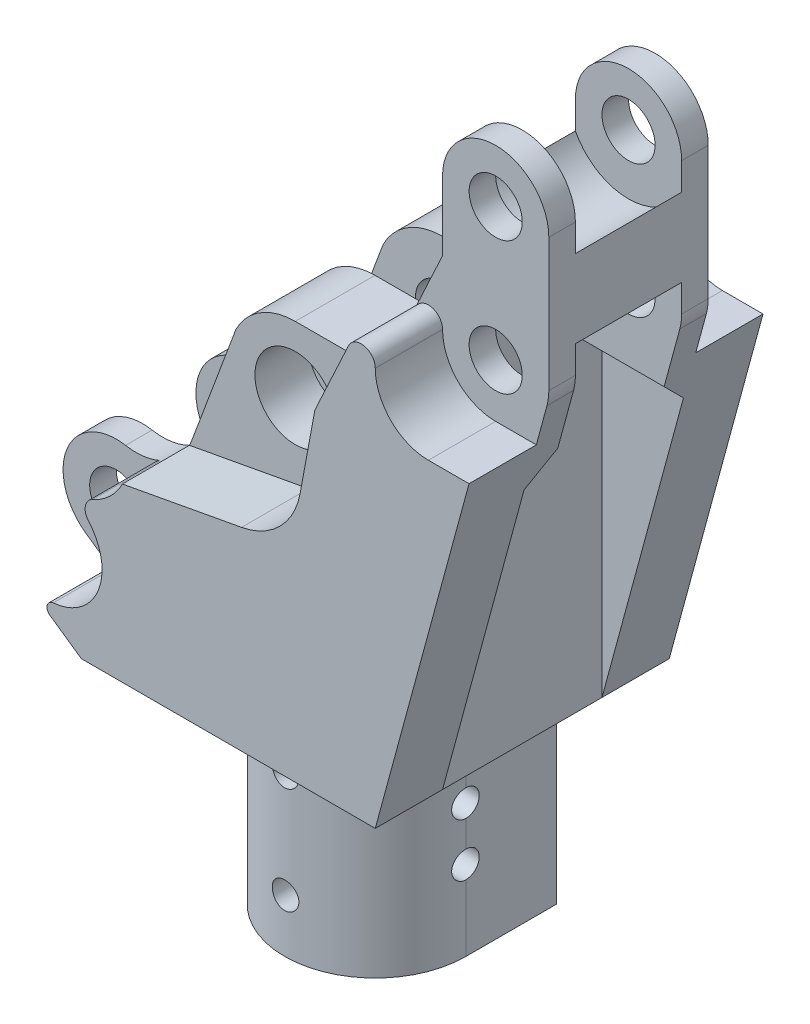
from build123d import *

# Parameters (mm, degrees)
BOSS_EXTRUDE1_BASE_DEPTH            = 17.5641
CUT_EXTRUDE2_DEPTH                  = 51.502975596
SKETCH5_R                           = 3.175
BOSS_EXTRUDE3_DEPTH                 = 35.1282
SKETCH6_R                           = 3.175
BOSS_EXTRUDE4_DEPTH                 = 35.1282
CUT_EXTRUDE3_START                  = -8.00735
CUT_EXTRUDE3_DEPTH                  = 8.00735
CUT_EXTRUDE54_START                 = -25.6032
CUT_EXTRUDE54_DEPTH                 = 8.07085
BOSS_EXTRUDE5_START                 = -9.525
BOSS_EXTRUDE5_DEPTH                 = 9.525
BOSS_EXTRUDE6_START                 = -27.12085
BOSS_EXTRUDE6_DEPTH                 = 9.525
CUT_EXTRUDE8_DEPTH                  = 80.824309426
CUT_EXTRUDE8_DEPTH_BACK             = 80.824309426
SKETCH13_W                          = 12.7
SKETCH13_H                          = 12.7
CUT_EXTRUDE9_START                  = -8.0391
CUT_EXTRUDE9_DEPTH                  = 8.0391
CUT_EXTRUDE10_START                 = -35.1282
CUT_EXTRUDE10_DEPTH                 = 8.0391
BOSS_EXTRUDE9_BOTTOMEXTRUSION_DEPTH = 25.4
SKETCH46_R                          = 6.35
CUT_EXTRUDE48_DEPTH                 = 38.1
CUT_EXTRUDE12_DEPTH                 = 76.038795802
CUT_EXTRUDE13_DEPTH                 = 76.038795802
BOSS_EXTRUDE7_DEPTH                 = 12.7
CUT_EXTRUDE29_DEPTH                 = 74.593672853
CUT_EXTRUDE29_DEPTH_BACK            = 74.593672853
SKETCH33_R                          = 3.2385
SKETCH31_R                          = 4.826
CUT_EXTRUDE38_DEPTH                 = 6.35
CUT_EXTRUDE39_START                 = -20.77085
SKETCH31_4_R                        = 4.826
CUT_EXTRUDE39_DEPTH                 = 6.35
SKETCH44_R                          = 1.5875
CUT_EXTRUDE40_BOTTOMHOLES_DEPTH     = 71.628883728
SKETCH45_R                          = 1.5875
CUT_EXTRUDE49_DEPTH                 = 73.550671727


with BuildPart() as part:
    # Sketch2 → Boss-Extrude1_Base (new, symmetric)
    with BuildSketch(Plane.XY):
        with BuildLine():
            Line((-7.105127648, 3.538512027), (-17.5641, -17.4625))
            Line((-17.5641, -17.4625), (-17.5641, -31.75))
            Line((-17.5641, -31.75), (17.5641, -31.75))
            Line((17.5641, -31.75), (17.5641, -17.4625))
            Line((17.5641, -17.4625), (7.105127648, 3.538512027))
            ThreePointArc((7.105127648, 3.538512027), (0, 7.9375), (-7.105127648, 3.538512027))
        make_face()
    extrude(amount=BOSS_EXTRUDE1_BASE_DEPTH, both=True)

    # Sketch9 → Cut-Extrude2 (cut, through all)
    with BuildSketch(Plane.XY.offset(17.5641)):
        with BuildLine():
            Line((-7.105127648, 3.538512027), (-12.357003511, -10.53649105))
            ThreePointArc((-12.357003511, -10.53649105), (-13.833909386, -12.920243592), (-16.11454497, -14.551877275))
            Line((-16.11454497, -14.551877275), (-7.105127648, 3.538512027))
        make_face()
    extrude(amount=-CUT_EXTRUDE2_DEPTH, mode=Mode.SUBTRACT)

    # Sketch5 → Boss-Extrude3 (add)
    with BuildSketch(Plane.XY.offset(17.5641)):
        with BuildLine():
            Line((-25.059087438, -26.532727902), (-17.5641, -31.75))
            Line((-17.5641, -31.75), (-17.5641, -17.4625))
            Line((-17.5641, -17.4625), (-16.11454497, -14.551877275))
            ThreePointArc((-16.11454497, -14.551877275), (-18.173337835, -15.128855109), (-20.310661765, -15.07073537))
            ThreePointArc((-20.310661765, -15.07073537), (-27.297756016, -18.890726679), (-25.059087438, -26.532727902))
        make_face()
        with Locations((-21.43125, -21.321077921)):
            Circle(SKETCH5_R, mode=Mode.SUBTRACT)
    extrude(amount=-BOSS_EXTRUDE3_DEPTH)

    # Sketch6 → Boss-Extrude4 (add)
    with BuildSketch(Plane.XY.offset(17.5641)):
        with BuildLine():
            Line((30.2641, 31.75), (30.2641, 15.875))
            ThreePointArc((30.2641, 15.875), (30.208397169, 15.035760377), (30.042265939, 14.211244541))
            Line((30.042265939, 14.211244541), (17.5641, -31.75))
            Line((17.5641, -31.75), (17.5641, -17.4625))
            Line((17.5641, -17.4625), (8.875846641, -0.016989378))
            Line((8.875846641, -0.016989378), (10.345315555, 7.9375))
            Line((10.345315555, 7.9375), (17.5641, 23.495))
            Line((17.5641, 23.495), (17.5641, 31.75))
            ThreePointArc((17.5641, 31.75), (23.9141, 38.1), (30.2641, 31.75))
        make_face()
        with Locations((23.9141, 15.875)):
            Circle(SKETCH6_R, mode=Mode.SUBTRACT)
        with Locations((23.9141, 31.75)):
            Circle(SKETCH6_R, mode=Mode.SUBTRACT)
    extrude(amount=-BOSS_EXTRUDE4_DEPTH)

    # Sketch8 → Cut-Extrude3 (cut)
    with BuildSketch(Plane.XY.offset(17.5641).offset(CUT_EXTRUDE3_START)):
        with BuildLine():
            Line((-7.105127648, 3.538512027), (-12.651612823, -11.216175006))
            Line((-12.651612823, -11.216175006), (1.586125742, -8.585972961))
            ThreePointArc((1.586125742, -8.585972961), (6.173926083, -6.173926083), (8.585972961, -1.586125742))
            Line((8.585972961, -1.586125742), (8.875846641, -0.016989378))
            Line((8.875846641, -0.016989378), (7.105127648, 3.538512027))
            ThreePointArc((7.105127648, 3.538512027), (0, 7.9375), (-7.105127648, 3.538512027))
        make_face()
    extrude(amount=CUT_EXTRUDE3_DEPTH, mode=Mode.SUBTRACT)

    # Sketch8_6 → Cut-Extrude54 (cut)
    with BuildSketch(Plane.XY.offset(17.5641).offset(CUT_EXTRUDE54_START)):
        with BuildLine():
            Line((-7.105127648, 3.538512027), (-12.651612823, -11.216175006))
            Line((-12.651612823, -11.216175006), (1.586125742, -8.585972961))
            ThreePointArc((1.586125742, -8.585972961), (6.173926083, -6.173926083), (8.585972961, -1.586125742))
            Line((8.585972961, -1.586125742), (8.875846641, -0.016989378))
            Line((8.875846641, -0.016989378), (7.105127648, 3.538512027))
            ThreePointArc((7.105127648, 3.538512027), (0, 7.9375), (-7.105127648, 3.538512027))
        make_face()
    extrude(amount=CUT_EXTRUDE54_DEPTH, mode=Mode.SUBTRACT)

    # Sketch50 → Boss-Extrude5 (add)
    with BuildSketch(Plane(origin=(0, 0, -17.5641), x_dir=(-1, 0, 0), z_dir=(0, 0, -1)).offset(BOSS_EXTRUDE5_START)):
        with BuildLine():
            Line((-10.345315555, 7.9375), (-8.875846641, -0.016989378))
            Line((-8.875846641, -0.016989378), (-7.105127648, 3.538512027))
            ThreePointArc((-7.105127648, 3.538512027), (-4.178335018, 6.748734899), (0, 7.9375))
            Line((0, 7.9375), (-10.345315555, 7.9375))
        make_face()
    extrude(amount=BOSS_EXTRUDE5_DEPTH)

    # Sketch50_2 → Boss-Extrude6 (add)
    with BuildSketch(Plane(origin=(0, 0, -17.5641), x_dir=(-1, 0, 0), z_dir=(0, 0, -1)).offset(BOSS_EXTRUDE6_START)):
        with BuildLine():
            Line((-10.345315555, 7.9375), (-8.875846641, -0.016989378))
            Line((-8.875846641, -0.016989378), (-7.105127648, 3.538512027))
            ThreePointArc((-7.105127648, 3.538512027), (-4.178335018, 6.748734899), (0, 7.9375))
            Line((0, 7.9375), (-10.345315555, 7.9375))
        make_face()
    extrude(amount=BOSS_EXTRUDE6_DEPTH)

    # Sketch13 → Cut-Extrude8 (cut, two sides: drawn at the far end of the back side and taken through both)
    with BuildSketch(Plane(origin=(-4.032455717, 0, -43.624597006), x_dir=(1, 0, 0), z_dir=(0, 1, 0)).offset(-CUT_EXTRUDE8_DEPTH_BACK)):
        with Locations((-17.398794283, -43.624597006)):
            Rectangle(SKETCH13_W, SKETCH13_H)
    extrude(amount=CUT_EXTRUDE8_DEPTH + CUT_EXTRUDE8_DEPTH_BACK, mode=Mode.SUBTRACT)

    # Sketch14 → Cut-Extrude9 (cut)
    with BuildSketch(Plane.XY.offset(17.5641).offset(CUT_EXTRUDE9_START)):
        with BuildLine():
            Line((-21.311593719, -29.141363951), (-25.059087438, -26.532727902))
            ThreePointArc((-25.059087438, -26.532727902), (-27.297756016, -18.890726679), (-20.310661765, -15.07073537))
            ThreePointArc((-20.310661765, -15.07073537), (-18.198707506, -15.131946054), (-16.161219582, -14.572713989))
            ThreePointArc((-16.161219582, -14.572713989), (-17.071234087, -15.690624185), (-16.701664703, -17.083918151))
            ThreePointArc((-16.701664703, -17.083918151), (-15.531976998, -23.670775358), (-20.910026182, -27.649650093))
            ThreePointArc((-20.910026182, -27.649650093), (-21.635249567, -28.254328522), (-21.311593719, -29.141363951))
        make_face()
        with BuildLine():
            Line((28.769982353, 9.525), (23.9141, 9.525))
            ThreePointArc((23.9141, 9.525), (19.423971939, 11.384871939), (17.5641, 15.875))
            ThreePointArc((17.5641, 15.875), (16.244791465, 17.517232787), (14.356818435, 16.582855256))
            Line((14.356818435, 16.582855256), (17.5641, 23.495))
            Line((17.5641, 23.495), (17.5641, 31.75))
            ThreePointArc((17.5641, 31.75), (23.9141, 38.1), (30.2641, 31.75))
            Line((30.2641, 31.75), (30.2641, 15.875))
            ThreePointArc((30.2641, 15.875), (30.208397169, 15.035760377), (30.042265939, 14.211244541))
            Line((30.042265939, 14.211244541), (28.769982353, 9.525))
        make_face()
    extrude(amount=CUT_EXTRUDE9_DEPTH, mode=Mode.SUBTRACT)

    # Sketch14_3 → Cut-Extrude10 (cut)
    with BuildSketch(Plane.XY.offset(17.5641).offset(CUT_EXTRUDE10_START)):
        with BuildLine():
            Line((-21.311593719, -29.141363951), (-25.059087438, -26.532727902))
            ThreePointArc((-25.059087438, -26.532727902), (-27.297756016, -18.890726679), (-20.310661765, -15.07073537))
            ThreePointArc((-20.310661765, -15.07073537), (-18.198707506, -15.131946054), (-16.161219582, -14.572713989))
            ThreePointArc((-16.161219582, -14.572713989), (-17.071234087, -15.690624185), (-16.701664703, -17.083918151))
            ThreePointArc((-16.701664703, -17.083918151), (-15.531976998, -23.670775358), (-20.910026182, -27.649650093))
            ThreePointArc((-20.910026182, -27.649650093), (-21.635249567, -28.254328522), (-21.311593719, -29.141363951))
        make_face()
        with BuildLine():
            Line((28.769982353, 9.525), (23.9141, 9.525))
            ThreePointArc((23.9141, 9.525), (19.423971939, 11.384871939), (17.5641, 15.875))
            ThreePointArc((17.5641, 15.875), (16.244791465, 17.517232787), (14.356818435, 16.582855256))
            Line((14.356818435, 16.582855256), (17.5641, 23.495))
            Line((17.5641, 23.495), (17.5641, 31.75))
            ThreePointArc((17.5641, 31.75), (23.9141, 38.1), (30.2641, 31.75))
            Line((30.2641, 31.75), (30.2641, 15.875))
            ThreePointArc((30.2641, 15.875), (30.208397169, 15.035760377), (30.042265939, 14.211244541))
            Line((30.042265939, 14.211244541), (28.769982353, 9.525))
        make_face()
    extrude(amount=CUT_EXTRUDE10_DEPTH, mode=Mode.SUBTRACT)

    # Sketch43 → Boss-Extrude9_BottomExtrusion (add)
    with BuildSketch(Plane.XZ.offset(31.75)):
        with BuildLine():
            Line((10.8331, -10.8331), (-10.8331, -10.8331))
            Line((-10.8331, -10.8331), (-10.8331, 0))
            ThreePointArc((-10.8331, 0), (0, 10.8331), (10.8331, 0))
            Line((10.8331, 0), (10.8331, -10.8331))
        make_face()
    extrude(amount=BOSS_EXTRUDE9_BOTTOMEXTRUSION_DEPTH)

    # Sketch46 → Cut-Extrude48 (cut)
    with BuildSketch(Plane.XZ.offset(57.15)):
        Circle(SKETCH46_R)
    extrude(amount=-CUT_EXTRUDE48_DEPTH, mode=Mode.SUBTRACT)

    # Sketch17 → Cut-Extrude12 (cut, through all)
    with BuildSketch(Plane.ZY.offset(15.08125)):
        Polygon((-9.888572019, -31.75), (-6.35, -31.75), (-6.35, -28.211427981), align=None)
        Polygon((9.888572019, -31.75), (6.35, -31.75), (6.35, -28.211427981), align=None)
    extrude(amount=CUT_EXTRUDE12_DEPTH, mode=Mode.SUBTRACT)

    # Sketch18 → Cut-Extrude13 (cut, through all)
    with BuildSketch(Plane(origin=(17.5641, 0, 0), x_dir=(0, 0, -1), z_dir=(1, 0, 0))):
        Polygon((-6.35, 7.3025), (-6.35, 38.1), (6.35, 38.1), (6.35, 7.3025), (9.525, 4.1275), (9.525, -31.75), (-9.525, -31.75), (-9.525, 4.1275), align=None)
    extrude(amount=CUT_EXTRUDE13_DEPTH, mode=Mode.SUBTRACT)

    # Sketch56 → Boss-Extrude7 (add)
    with BuildSketch(Plane(origin=(0, 0, 6.35), x_dir=(-1, 0, 0), z_dir=(0, 0, -1))):
        with BuildLine():
            Line((-17.5641, 28.47728491), (-17.5641, 19.14771509))
            ThreePointArc((-17.5641, 19.14771509), (-23.9141, 23.01875), (-30.2641, 19.14771509))
            Line((-30.2641, 19.14771509), (-30.2641, 28.47728491))
            ThreePointArc((-30.2641, 28.47728491), (-23.9141, 24.60625), (-17.5641, 28.47728491))
        make_face()
    extrude(amount=BOSS_EXTRUDE7_DEPTH)

    # Sketch33 → Cut-Extrude29 (cut, two sides: drawn at the far end of the back side and taken through both)
    with BuildSketch(Plane(origin=(0, 0, -17.5641), x_dir=(-1, 0, 0), z_dir=(0, 0, -1)).offset(-CUT_EXTRUDE29_DEPTH_BACK)):
        Circle(SKETCH33_R)
    extrude(amount=CUT_EXTRUDE29_DEPTH + CUT_EXTRUDE29_DEPTH_BACK, mode=Mode.SUBTRACT)

    # Sketch31 → Cut-Extrude38 (cut)
    with BuildSketch(Plane(origin=(0, 0, -17.5641), x_dir=(-1, 0, 0), z_dir=(0, 0, -1))):
        Circle(SKETCH31_R)
    extrude(amount=-CUT_EXTRUDE38_DEPTH, mode=Mode.SUBTRACT)

    # Sketch31_4 → Cut-Extrude39 (cut)
    with BuildSketch(Plane(origin=(0, 0, -17.5641), x_dir=(-1, 0, 0), z_dir=(0, 0, -1)).offset(CUT_EXTRUDE39_START)):
        Circle(SKETCH31_4_R)
    extrude(amount=-CUT_EXTRUDE39_DEPTH, mode=Mode.SUBTRACT)

    # Sketch44 → Cut-Extrude40_BottomHoles (cut, through all)
    with BuildSketch(Plane(origin=(0, 0, -10.8331), x_dir=(-1, 0, 0), z_dir=(0, 0, -1))):
        with Locations((0, -38.1)):
            Circle(SKETCH44_R)
        with Locations((0, -50.8)):
            Circle(SKETCH44_R)
    extrude(amount=-CUT_EXTRUDE40_BOTTOMHOLES_DEPTH, mode=Mode.SUBTRACT)

    # Sketch45 → Cut-Extrude49 (cut, through all)
    with BuildSketch(Plane.ZY.offset(10.8331)):
        with Locations(Location((0, -41.275, 0), (0, 0, 270))):
            Circle(SKETCH45_R)
        with Locations(Location((0, -47.625, 0), (0, 0, 270))):
            Circle(SKETCH45_R)
    extrude(amount=-CUT_EXTRUDE49_DEPTH, mode=Mode.SUBTRACT)


solid = part.part
